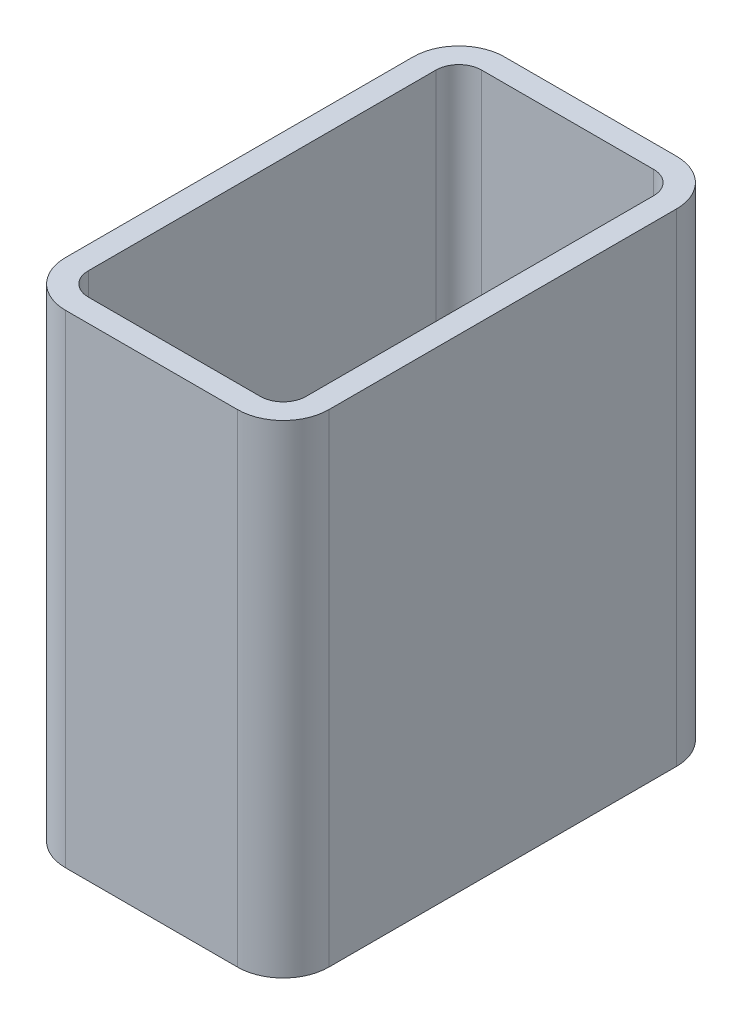
from build123d import *

# Parameters (mm, degrees)
RECTANGULAR_TUBE_50_X_30_X_2_6_1_DEPTH = 55


with BuildPart() as part:
    # Sketch11 → Rectangular tube 50 X 30 X 2.6_1 (new body)
    with BuildSketch(Plane(origin=(15, 0, 25), x_dir=(-1, 0, 0), z_dir=(0, 1, 0))):
        with BuildLine():
            Line((-9.8, -25), (9.8, -25))
            ThreePointArc((9.8, -25), (13.476955262, -23.476955262), (15, -19.8))
            Line((15, -19.8), (15, 19.8))
            ThreePointArc((15, 19.8), (13.476955262, 23.476955262), (9.8, 25))
            Line((9.8, 25), (-9.8, 25))
            ThreePointArc((-9.8, 25), (-13.476955262, 23.476955262), (-15, 19.8))
            Line((-15, 19.8), (-15, -19.8))
            ThreePointArc((-15, -19.8), (-13.476955262, -23.476955262), (-9.8, -25))
        make_face()
        with BuildLine():
            Line((-9.8, -22.4), (9.8, -22.4))
            ThreePointArc((9.8, -22.4), (11.638477631, -21.638477631), (12.4, -19.8))
            Line((12.4, -19.8), (12.4, 19.8))
            ThreePointArc((12.4, 19.8), (11.638477631, 21.638477631), (9.8, 22.4))
            Line((9.8, 22.4), (-9.8, 22.4))
            ThreePointArc((-9.8, 22.4), (-11.638477631, 21.638477631), (-12.4, 19.8))
            Line((-12.4, 19.8), (-12.4, -19.8))
            ThreePointArc((-12.4, -19.8), (-11.638477631, -21.638477631), (-9.8, -22.4))
        make_face(mode=Mode.SUBTRACT)
    extrude(amount=RECTANGULAR_TUBE_50_X_30_X_2_6_1_DEPTH)


solid = part.part
